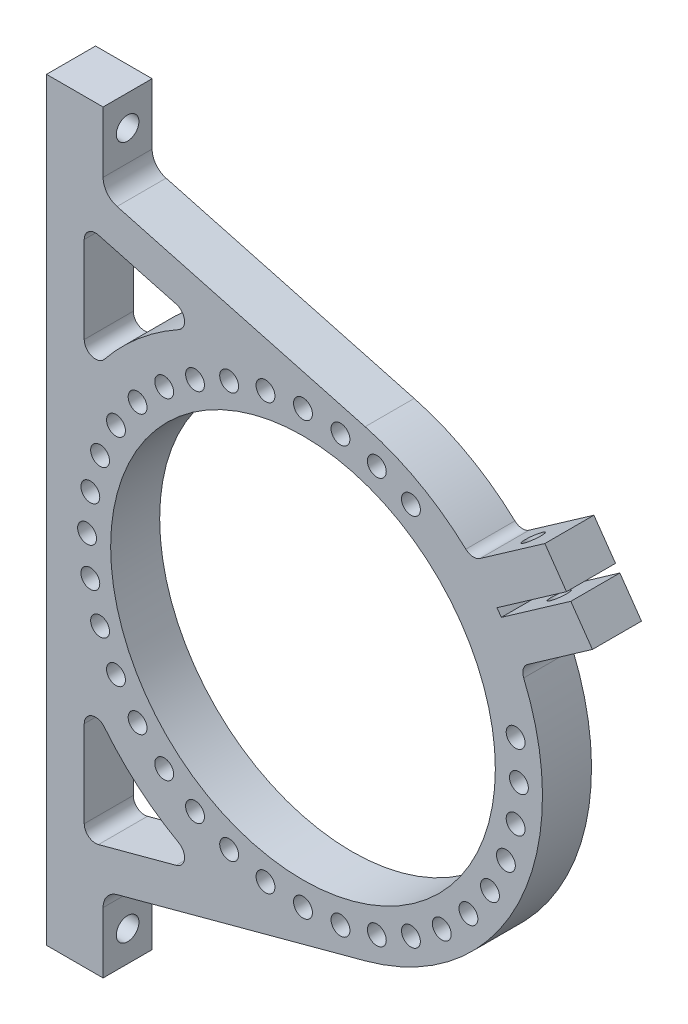
from build123d import *

# Parameters (mm, degrees)
SKETCH1_R           = 51
BOSS_EXTRUDE1_DEPTH = 13
FILLET1_R           = 5
BOSS_EXTRUDE2_DEPTH = 13
SKETCH3_R           = 2.5
CUT_EXTRUDE1_DEPTH  = 13
SKETCH4_R           = 3
CUT_EXTRUDE2_DEPTH  = 16
SKETCH5_R           = 2.5
CUT_EXTRUDE3_DEPTH  = 132.918402101
FILLET2_R           = 3
CUT_EXTRUDE4_DEPTH  = 14
CUT_EXTRUDE5_DEPTH  = 14
FILLET3_R           = 3


with BuildPart() as part:
    # Sketch1 → Boss-Extrude1 (new body)
    with BuildSketch(Plane.XY):
        with BuildLine():
            Line((0, 0), (0, 200))
            Line((0, 200), (15, 200))
            Line((15, 200), (15, 180))
            Line((15, 180), (84.483320298, 161.323324697))
            ThreePointArc((84.483320298, 161.323324697), (131.5, 100), (84.483320298, 38.676675303))
            Line((84.483320298, 38.676675303), (15, 20))
            Line((15, 20), (15, 0))
            Line((15, 0), (0, 0))
        make_face()
        with Locations((68, 100)):
            Circle(SKETCH1_R, mode=Mode.SUBTRACT)
    extrude(amount=BOSS_EXTRUDE1_DEPTH)

    # Fillet1
    fillet1_edges = [part.edges().sort_by_distance(p)[0] for p in [
        (15, 180, 6.5),
        (15, 20, 6.5),
    ]]
    fillet(fillet1_edges, radius=FILLET1_R)

    # Sketch2 → Boss-Extrude2 (add)
    with BuildSketch(Plane.XY.offset(13)):
        with BuildLine():
            ThreePointArc((112.920417572, 144.882135479), (116.329690544, 141.188481545), (119.43612796, 137.236739123))
            Line((119.43612796, 137.236739123), (137.865467698, 150.141101731))
            Line((137.865467698, 150.141101731), (132.129703335, 158.332622174))
            Line((132.129703335, 158.332622174), (112.920417572, 144.882135479))
        make_face()
        with BuildLine():
            Line((139.012620571, 148.502797643), (120.583280833, 135.598435034))
            ThreePointArc((120.583280833, 135.598435034), (123.234239855, 131.327763208), (125.539099171, 126.860790505))
            Line((125.539099171, 126.860790505), (144.748384934, 140.3112772))
            Line((144.748384934, 140.3112772), (139.012620571, 148.502797643))
        make_face()
    extrude(amount=-BOSS_EXTRUDE2_DEPTH)

    # Sketch3 → Cut-Extrude1 (cut)
    with BuildSketch(Plane.XY.offset(13)):
        with Locations((96.625, 149.579954367)):
            Circle(SKETCH3_R)
        with Locations((124.38024386, 109.941358171)):
            Circle(SKETCH3_R)
        with Locations((87.580653205, 153.79740254)):
            Circle(SKETCH3_R)
        with Locations((77.941358171, 156.38024386)):
            Circle(SKETCH3_R)
        with Locations((68, 157.25)):
            Circle(SKETCH3_R)
        with Locations((58.058641829, 156.38024386)):
            Circle(SKETCH3_R)
        with Locations((48.419346795, 153.79740254)):
            Circle(SKETCH3_R)
        with Locations((39.375, 149.579954367)):
            Circle(SKETCH3_R)
        with Locations((31.200409345, 143.856044369)):
            Circle(SKETCH3_R)
        with Locations((24.143955631, 136.799590655)):
            Circle(SKETCH3_R)
        with Locations((18.420045633, 128.625)):
            Circle(SKETCH3_R)
        with Locations((14.20259746, 119.580653205)):
            Circle(SKETCH3_R)
        with Locations((11.61975614, 109.941358171)):
            Circle(SKETCH3_R)
        with Locations((10.75, 100)):
            Circle(SKETCH3_R)
        with Locations((11.61975614, 90.058641829)):
            Circle(SKETCH3_R)
        with Locations((14.20259746, 80.419346795)):
            Circle(SKETCH3_R)
        with Locations((18.420045633, 71.375)):
            Circle(SKETCH3_R)
        with Locations((24.143955631, 63.200409345)):
            Circle(SKETCH3_R)
        with Locations((31.200409345, 56.143955631)):
            Circle(SKETCH3_R)
        with Locations((39.375, 50.420045633)):
            Circle(SKETCH3_R)
        with Locations((48.419346795, 46.20259746)):
            Circle(SKETCH3_R)
        with Locations((58.058641829, 43.61975614)):
            Circle(SKETCH3_R)
        with Locations((68, 42.75)):
            Circle(SKETCH3_R)
        with Locations((77.941358171, 43.61975614)):
            Circle(SKETCH3_R)
        with Locations((87.580653205, 46.20259746)):
            Circle(SKETCH3_R)
        with Locations((96.625, 50.420045633)):
            Circle(SKETCH3_R)
        with Locations((104.799590655, 56.143955631)):
            Circle(SKETCH3_R)
        with Locations((111.856044369, 63.200409345)):
            Circle(SKETCH3_R)
        with Locations((117.579954367, 71.375)):
            Circle(SKETCH3_R)
        with Locations((121.79740254, 80.419346795)):
            Circle(SKETCH3_R)
        with Locations((124.38024386, 90.058641829)):
            Circle(SKETCH3_R)
        with Locations((125.25, 100)):
            Circle(SKETCH3_R)
    extrude(amount=-CUT_EXTRUDE1_DEPTH, mode=Mode.SUBTRACT)

    # Sketch4 → Cut-Extrude2 (cut, through all)
    with BuildSketch(Plane(origin=(15, 0, 0), x_dir=(0, 0, -1), z_dir=(1, 0, 0))):
        with Locations((-6.5, 191.916753533)):
            Circle(SKETCH4_R)
        with Locations((-6.5, 8.083246467)):
            Circle(SKETCH4_R)
    extrude(amount=-CUT_EXTRUDE2_DEPTH, mode=Mode.SUBTRACT)

    # Sketch5 → Cut-Extrude3 (cut, through all)
    with BuildSketch(Plane(origin=(-18.303975113, 26.140785572, 0), x_dir=(0.819152044, 0.573576436, 0), z_dir=(0.573576436, -0.819152044, 0))):
        with Locations((187.325073819, 6.5)):
            Circle(SKETCH5_R)
    extrude(amount=-CUT_EXTRUDE3_DEPTH, mode=Mode.SUBTRACT)

    # Fillet2
    fillet2_edges = [part.edges().sort_by_distance(p)[0] for p in [
        (112.920417572, 144.882135479, 6.5),
        (125.539099171, 126.860790505, 6.5),
    ]]
    fillet(fillet2_edges, radius=FILLET2_R)

    # Sketch6 → Cut-Extrude4 (cut, through all)
    with BuildSketch(Plane.XY.offset(13)):
        with BuildLine():
            Line((42.140126878, 162.34995559), (10, 170.989017617))
            Line((10, 170.989017617), (10, 134.528973341))
            ThreePointArc((10, 134.528973341), (23.822841385, 151.035562666), (42.140126878, 162.34995559))
        make_face()
    extrude(amount=-CUT_EXTRUDE4_DEPTH, mode=Mode.SUBTRACT)

    # Sketch7 → Cut-Extrude5 (cut, through all)
    with BuildSketch(Plane.XY.offset(13)):
        with BuildLine():
            Line((16.106302292, 30.652317666), (10, 29.010982383))
            Line((10, 29.010982383), (10, 65.471026659))
            ThreePointArc((10, 65.471026659), (23.822841385, 48.964437334), (42.140126878, 37.65004441))
            Line((42.140126878, 37.65004441), (16.106302292, 30.652317666))
        make_face()
    extrude(amount=-CUT_EXTRUDE5_DEPTH, mode=Mode.SUBTRACT)

    # Fillet3
    fillet3_edges = [part.edges().sort_by_distance(p)[0] for p in [
        (10, 134.528973341, 6.5),
        (10, 170.989017617, 6.5),
        (42.140126878, 162.34995559, 6.5),
        (10, 65.471026659, 6.5),
        (42.140126878, 37.65004441, 6.5),
        (10, 29.010982383, 6.5),
    ]]
    fillet(fillet3_edges, radius=FILLET3_R)


solid = part.part
